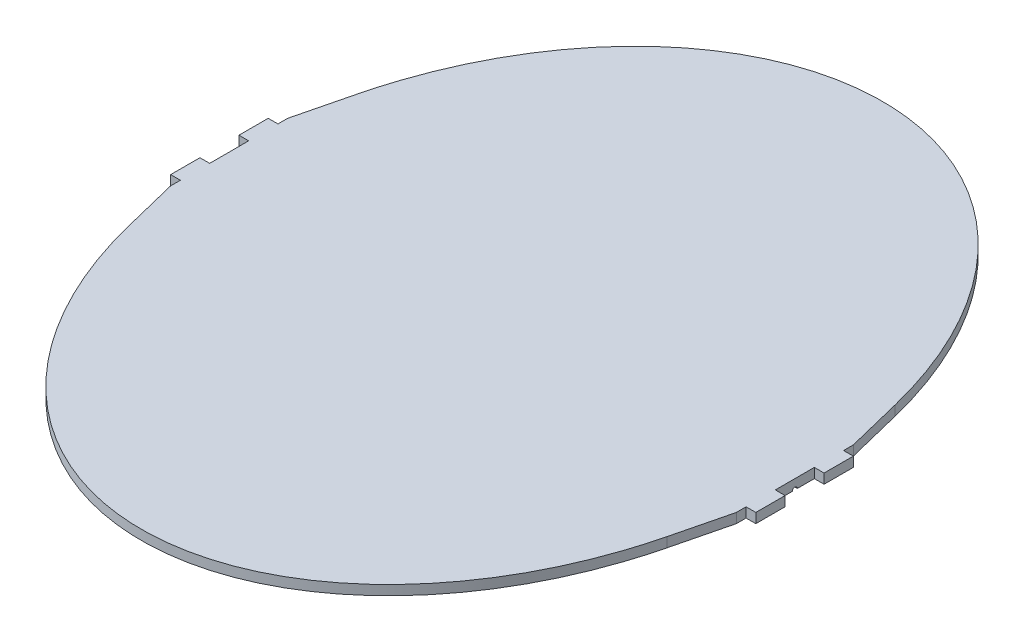
from build123d import *

# Parameters (mm, degrees)
SKETCH1_RX          = 380
SKETCH1_RY          = 290
BOSS_EXTRUDE1_DEPTH = 10
BOSS_EXTRUDE2_DEPTH = 10
CUT_EXTRUDE1_DEPTH  = 10
CUT_EXTRUDE2_DEPTH  = 10


with BuildPart() as part:
    # Sketch1 → Boss-Extrude1 (new body)
    with BuildSketch(Plane(origin=(0, 0, 0), x_dir=(1, 0, 0), z_dir=(0, 1, 0))):
        with Locations(Location((0, 0), (0, 0, 90))):
            Ellipse(SKETCH1_RX, SKETCH1_RY)
    extrude(amount=BOSS_EXTRUDE1_DEPTH)

    # Sketch2 → Boss-Extrude2 (add)
    with BuildSketch(Plane(origin=(0, 10, 0), x_dir=(-1, 0, 0), z_dir=(0, 1, 0))):
        Polygon((-275.891891892, -117.081081081), (-290, -60), (-290, -50), (-300, -50), (-300, -20), (-290, -20), (-290, 0), (-290, 20), (-300, 20), (-300, 50), (-290, 50), (-290, 60), (-275.891891892, 117.081081081), align=None)
        Polygon((275.891891892, 117.081081081), (275.891891892, -117.081081081), (290, -60), (290, -50), (300, -50), (300, -20), (290, -20), (290, 0), (290, 20), (300, 20), (300, 50), (290, 50), (290, 60), align=None)
    extrude(amount=-BOSS_EXTRUDE2_DEPTH)

    # Sketch3 → Cut-Extrude1 (cut)
    with BuildSketch(Plane(origin=(290, 0, 0), x_dir=(0, 0, -1), z_dir=(1, 0, 0))):
        with BuildLine():
            Line((-2.5, 0), (2.5, 0))
            ThreePointArc((2.5, 0), (0, 2.5), (-2.5, 0))
        make_face()
    extrude(amount=-CUT_EXTRUDE1_DEPTH, mode=Mode.SUBTRACT)

    # Sketch4 → Cut-Extrude2 (cut)
    with BuildSketch(Plane.ZY.offset(290)):
        with BuildLine():
            Line((-57.5, 0), (-52.5, 0))
            ThreePointArc((-52.5, 0), (-55, 2.5), (-57.5, 0))
        make_face()
    extrude(amount=-CUT_EXTRUDE2_DEPTH, mode=Mode.SUBTRACT)


solid = part.part
